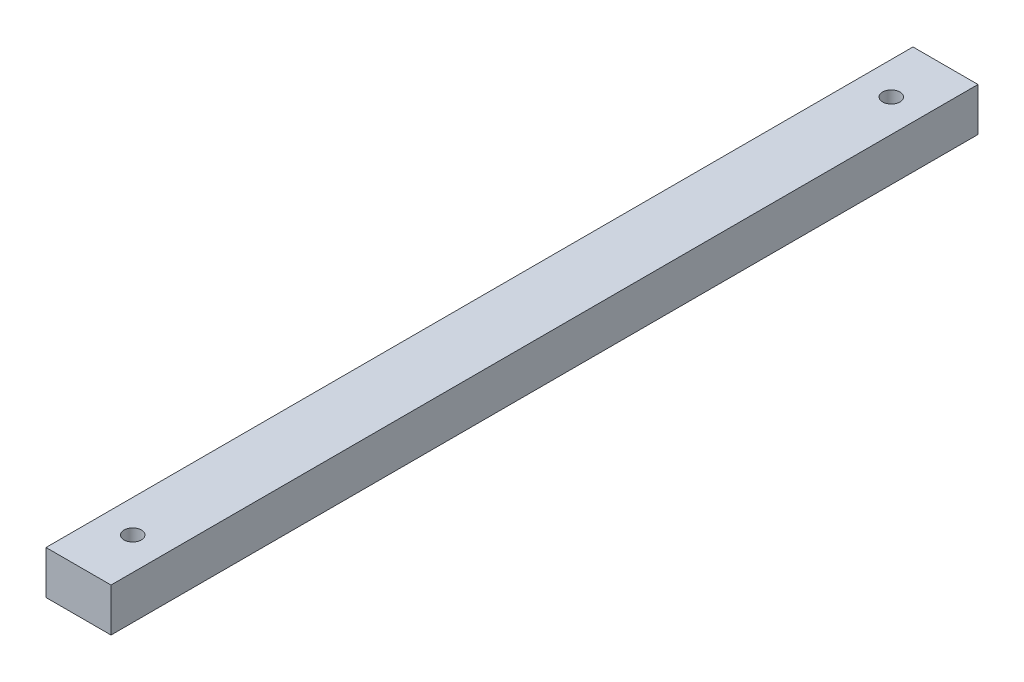
from build123d import *

# Parameters (mm, degrees)
CROQUIS1_W              = 30
CROQUIS1_H              = 20
SALIENTE_EXTRUIR1_DEPTH = 400
CROQUIS2_R              = 4
CORTAR_EXTRUIR1_DEPTH   = 400


with BuildPart() as part:
    # Croquis1 → Saliente-Extruir1 (new body)
    with BuildSketch(Plane.XY):
        Rectangle(CROQUIS1_W, CROQUIS1_H)
    extrude(amount=SALIENTE_EXTRUIR1_DEPTH)

    # Croquis2 → Cortar-Extruir1 (cut)
    with BuildSketch(Plane(origin=(0, 10, 0), x_dir=(1, 0, 0), z_dir=(0, 1, 0))):
        with Locations((0, -375)):
            Circle(CROQUIS2_R)
        with Locations((0, -25)):
            Circle(CROQUIS2_R)
    extrude(amount=-CORTAR_EXTRUIR1_DEPTH, mode=Mode.SUBTRACT)


solid = part.part
